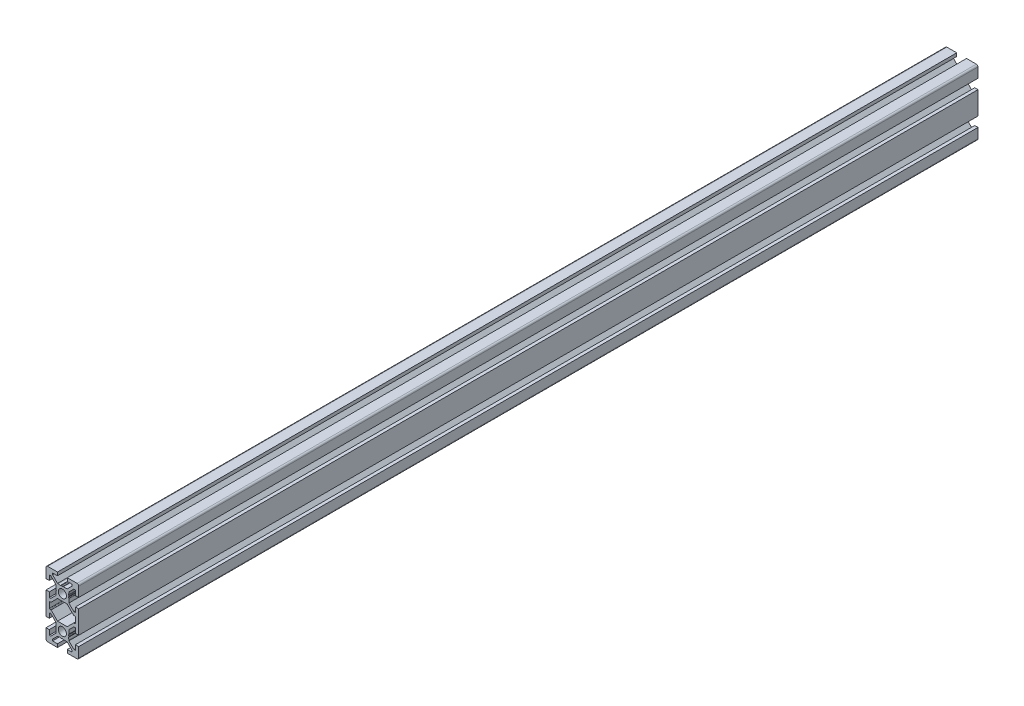
from build123d import *

# Parameters (mm, degrees)
SKETCH1_R           = 2.5
BOSS_EXTRUDE1_DEPTH = 550


with BuildPart() as part:
    # Sketch1 → Boss-Extrude1 (new body)
    with BuildSketch(Plane(origin=(0, 0, -600), x_dir=(-1, 0, 0), z_dir=(0, 0, -1))):
        with BuildLine():
            Line((10, -7), (10, 7))
            Line((10, 7), (8, 7))
            Line((8, 7), (8, 4))
            Line((8, 4), (7.060660172, 4))
            Line((7.060660172, 4), (4, 7.060660172))
            Line((4, 7.060660172), (4, 7.5))
            Line((4, 7.5), (3.750976592, 8.781114371))
            Line((3.750976592, 8.781114371), (3.933012702, 9.096410162))
            ThreePointArc((3.933012702, 9.096410162), (4, 9.346410162), (3.933012702, 9.596410162))
            Line((3.933012702, 9.596410162), (3.7, 10))
            Line((3.7, 10), (3.933012702, 10.403589838))
            ThreePointArc((3.933012702, 10.403589838), (3.982962913, 10.524180316), (4, 10.653589838))
            Line((4, 10.653589838), (4, 12.939339828))
            Line((4, 12.939339828), (7.060660172, 16))
            Line((7.060660172, 16), (8, 16))
            Line((8, 16), (8, 13))
            Line((8, 13), (10, 13))
            Line((10, 13), (10, 19))
            ThreePointArc((10, 19), (9.707106781, 19.707106781), (9, 20))
            Line((9, 20), (3, 20))
            Line((3, 20), (3, 18))
            Line((3, 18), (6, 18))
            Line((6, 18), (6, 17.060660172))
            Line((6, 17.060660172), (2.939339828, 14))
            Line((2.939339828, 14), (2.5, 14))
            Line((2.5, 14), (1.218885629, 13.750976592))
            Line((1.218885629, 13.750976592), (0.903589838, 13.933012702))
            ThreePointArc((0.903589838, 13.933012702), (0.653589838, 14), (0.403589838, 13.933012702))
            Line((0.403589838, 13.933012702), (0, 13.7))
            Line((0, 13.7), (-0.403589838, 13.933012702))
            ThreePointArc((-0.403589838, 13.933012702), (-0.524180316, 13.982962913), (-0.653589838, 14))
            Line((-0.653589838, 14), (-2.939339828, 14))
            Line((-2.939339828, 14), (-6, 17.060660172))
            Line((-6, 17.060660172), (-6, 18))
            Line((-6, 18), (-3, 18))
            Line((-3, 18), (-3, 20))
            Line((-3, 20), (-9, 20))
            ThreePointArc((-9, 20), (-9.707106781, 19.707106781), (-10, 19))
            Line((-10, 19), (-10, 13))
            Line((-10, 13), (-8, 13))
            Line((-8, 13), (-8, 16))
            Line((-8, 16), (-7.060660172, 16))
            Line((-7.060660172, 16), (-4, 12.939339828))
            Line((-4, 12.939339828), (-4, 12.5))
            Line((-4, 12.5), (-3.750976592, 11.218885629))
            Line((-3.750976592, 11.218885629), (-3.933012702, 10.903589838))
            ThreePointArc((-3.933012702, 10.903589838), (-4, 10.653589838), (-3.933012702, 10.403589838))
            Line((-3.933012702, 10.403589838), (-3.7, 10))
            Line((-3.7, 10), (-3.933012702, 9.596410162))
            ThreePointArc((-3.933012702, 9.596410162), (-3.982962913, 9.475819684), (-4, 9.346410162))
            Line((-4, 9.346410162), (-4, 7.060660172))
            Line((-4, 7.060660172), (-7.060660172, 4))
            Line((-7.060660172, 4), (-8, 4))
            Line((-8, 4), (-8, 7))
            Line((-8, 7), (-10, 7))
            Line((-10, 7), (-10, -7))
            Line((-10, -7), (-8, -7))
            Line((-8, -7), (-8, -4))
            Line((-8, -4), (-7.060660172, -4))
            Line((-7.060660172, -4), (-4, -7.060660172))
            Line((-4, -7.060660172), (-4, -9.346410162))
            ThreePointArc((-4, -9.346410162), (-3.982962913, -9.475819684), (-3.933012702, -9.596410162))
            Line((-3.933012702, -9.596410162), (-3.7, -10))
            Line((-3.7, -10), (-3.933012702, -10.403589838))
            ThreePointArc((-3.933012702, -10.403589838), (-4, -10.653589838), (-3.933012702, -10.903589838))
            Line((-3.933012702, -10.903589838), (-3.750976592, -11.218885629))
            Line((-3.750976592, -11.218885629), (-4, -12.5))
            Line((-4, -12.5), (-4, -12.939339828))
            Line((-4, -12.939339828), (-7.060660172, -16))
            Line((-7.060660172, -16), (-8, -16))
            Line((-8, -16), (-8, -13))
            Line((-8, -13), (-10, -13))
            Line((-10, -13), (-10, -19))
            ThreePointArc((-10, -19), (-9.707106781, -19.707106781), (-9, -20))
            Line((-9, -20), (-3, -20))
            Line((-3, -20), (-3, -18))
            Line((-3, -18), (-6, -18))
            Line((-6, -18), (-6, -17.060660172))
            Line((-6, -17.060660172), (-2.939339828, -14))
            Line((-2.939339828, -14), (-0.653589838, -14))
            ThreePointArc((-0.653589838, -14), (-0.524180316, -13.982962913), (-0.403589838, -13.933012702))
            Line((-0.403589838, -13.933012702), (0, -13.7))
            Line((0, -13.7), (0.403589839, -13.933012702))
            ThreePointArc((0.403589839, -13.933012702), (0.653589839, -14), (0.903589838, -13.933012702))
            Line((0.903589838, -13.933012702), (1.218885629, -13.750976592))
            Line((1.218885629, -13.750976592), (2.5, -14))
            Line((2.5, -14), (2.939339828, -14))
            Line((2.939339828, -14), (6, -17.060660172))
            Line((6, -17.060660172), (6, -18))
            Line((6, -18), (3, -18))
            Line((3, -18), (3, -20))
            Line((3, -20), (9, -20))
            ThreePointArc((9, -20), (9.707106781, -19.707106781), (10, -19))
            Line((10, -19), (10, -13))
            Line((10, -13), (8, -13))
            Line((8, -13), (8, -16))
            Line((8, -16), (7.060660172, -16))
            Line((7.060660172, -16), (4, -12.939339828))
            Line((4, -12.939339828), (4, -10.653589838))
            ThreePointArc((4, -10.653589838), (3.982962913, -10.524180316), (3.933012702, -10.403589838))
            Line((3.933012702, -10.403589838), (3.7, -10))
            Line((3.7, -10), (3.933012702, -9.596410162))
            ThreePointArc((3.933012702, -9.596410162), (4, -9.346410162), (3.933012702, -9.096410162))
            Line((3.933012702, -9.096410162), (3.750976592, -8.781114371))
            Line((3.750976592, -8.781114371), (4, -7.5))
            Line((4, -7.5), (4, -7.060660172))
            Line((4, -7.060660172), (7.060660172, -4))
            Line((7.060660172, -4), (8, -4))
            Line((8, -4), (8, -7))
            Line((8, -7), (10, -7))
        make_face()
        with Locations((0, -10)):
            Circle(SKETCH1_R, mode=Mode.SUBTRACT)
        with Locations((0, 10)):
            Circle(SKETCH1_R, mode=Mode.SUBTRACT)
        with BuildLine():
            Line((8, 1.7), (8, -1.7))
            ThreePointArc((8, -1.7), (7.912132034, -1.912132034), (7.7, -2))
            Line((7.7, -2), (7.063603897, -2))
            ThreePointArc((7.063603897, -2), (6.948798867, -2.02283614), (6.851471863, -2.087867966))
            Line((6.851471863, -2.087867966), (2.939339828, -6))
            Line((2.939339828, -6), (-2.939339828, -6))
            Line((-2.939339828, -6), (-6.851471863, -2.087867966))
            ThreePointArc((-6.851471863, -2.087867966), (-6.948798867, -2.02283614), (-7.063603897, -2))
            Line((-7.063603897, -2), (-7.7, -2))
            ThreePointArc((-7.7, -2), (-7.912132034, -1.912132034), (-8, -1.7))
            Line((-8, -1.7), (-8, 1.7))
            ThreePointArc((-8, 1.7), (-7.912132034, 1.912132034), (-7.7, 2))
            Line((-7.7, 2), (-7.063603897, 2))
            ThreePointArc((-7.063603897, 2), (-6.948798867, 2.02283614), (-6.851471863, 2.087867966))
            Line((-6.851471863, 2.087867966), (-2.939339828, 6))
            Line((-2.939339828, 6), (2.939339828, 6))
            Line((2.939339828, 6), (6.851471863, 2.087867966))
            ThreePointArc((6.851471863, 2.087867966), (6.948798867, 2.02283614), (7.063603897, 2))
            Line((7.063603897, 2), (7.7, 2))
            ThreePointArc((7.7, 2), (7.912132034, 1.912132034), (8, 1.7))
        make_face(mode=Mode.SUBTRACT)
    extrude(amount=-BOSS_EXTRUDE1_DEPTH)


solid = part.part
